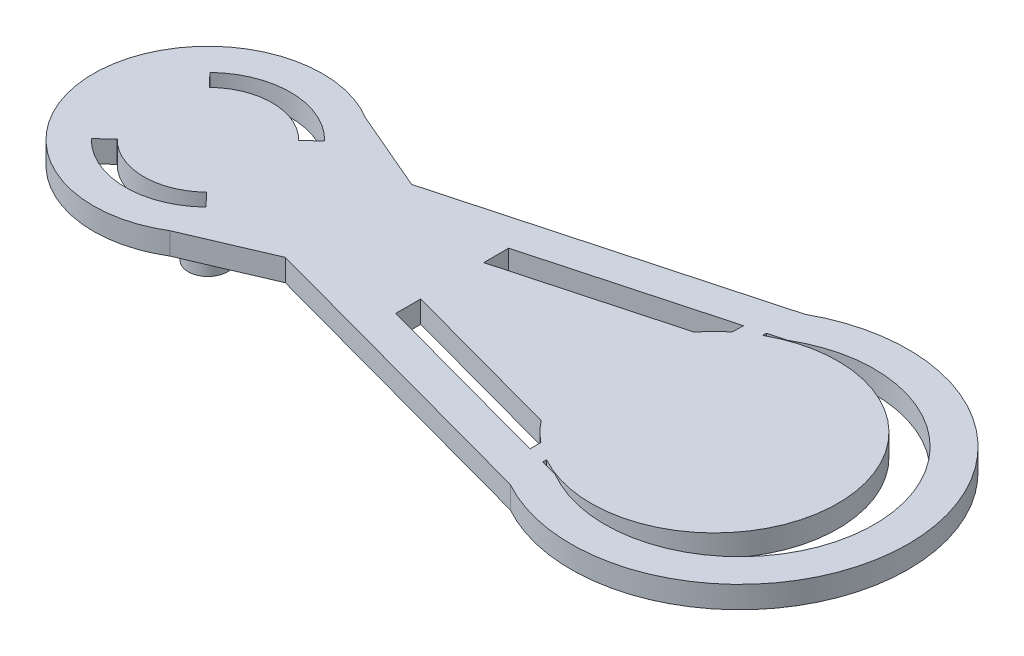
from build123d import *

# Parameters (mm, degrees)
BOSS_EXTRUDE1_DEPTH = 2.4
BOSS_EXTRUDE2_DEPTH = 9
SKETCH2_R           = 2.150011747
BOSS_EXTRUDE3_DEPTH = 9
CUT_EXTRUDE1_DEPTH  = 10


with BuildPart() as part:
    # Sketch1 → Boss-Extrude1 (new body)
    with BuildSketch(Plane(origin=(0, 0, 0), x_dir=(1, 0, 0), z_dir=(0, 1, 0))):
        with BuildLine():
            Line((-39.556221528, -6.891215643), (-5.823918226, -16.078704856))
            ThreePointArc((-5.823918226, -16.078704856), (21.515277807, 0.00207027), (-5.827536633, 16.076692097))
            Line((-5.827536633, 16.076692097), (-39.556221528, 6.891215643))
            Line((-39.556221528, 6.891215643), (-48.371159118, 10.670216357))
            ThreePointArc((-48.371159118, 10.670216357), (-67.382417284, 0), (-48.371159118, -10.670216357))
            Line((-48.371159118, -10.670216357), (-39.556221528, -6.891215643))
        make_face()
        with BuildLine():
            Line((-8.122758878, -10.441521159), (-8.105229312, -11.643301988))
            Line((-8.105229312, -11.643301988), (-28.234913418, -6.160686291))
            Line((-28.234913418, -6.160686291), (-28.234913418, -3.434881235))
            Line((-28.234913418, -3.434881235), (-26.602273601, -3.879554715))
            Line((-26.602273601, -3.879554715), (-10.183921919, -8.35133441))
            ThreePointArc((-10.183921919, -8.35133441), (-9.210480376, -9.452774334), (-8.122758878, -10.441521159))
        make_face(mode=Mode.SUBTRACT)
        with BuildLine():
            Line((-28.234913418, 6.161641155), (-8.104625251, 11.643808294))
            Line((-8.104625251, 11.643808294), (-8.119473087, 10.444385808))
            ThreePointArc((-8.119473087, 10.444385808), (-9.209489158, 9.453970662), (-10.184798219, 8.350417567))
            Line((-10.184798219, 8.350417567), (-26.60206646, 3.879432964))
            Line((-26.60206646, 3.879432964), (-28.234913418, 3.434752795))
            Line((-28.234913418, 3.434752795), (-28.234913418, 6.161641155))
        make_face(mode=Mode.SUBTRACT)
        with BuildLine():
            Line((-4.336944207, -12.669649891), (-6.180251244, -12.167598093))
            Line((-6.180251244, -12.167598093), (-6.180251244, -11.758725803))
            ThreePointArc((-6.180251244, -11.758725803), (13.838310708, -0.01960386), (-6.145811005, 11.778052091))
            Line((-6.145811005, 11.778052091), (-6.145811005, 12.177260522))
            Line((-6.145811005, 12.177260522), (-4.336225757, 12.670072583))
            ThreePointArc((-4.336225757, 12.670072583), (17.81758271, -0.000416785), (-4.336944207, -12.669649891))
        make_face(mode=Mode.SUBTRACT)
    extrude(amount=BOSS_EXTRUDE1_DEPTH)



with BuildPart() as body_2:
    # Sketch1_4 → Boss-Extrude2 (new body)
    with BuildSketch(Plane(origin=(0, 0, 0), x_dir=(1, 0, 0), z_dir=(0, 1, 0))):
        with BuildLine():
            ThreePointArc((-57.032417284, 0), (-54.882417284, -2.15), (-52.732417284, 0))
            Line((-52.732417284, 0), (-57.032417284, 0))
        make_face()
        with BuildLine():
            Line((-57.032417284, 0), (-52.732417284, 0))
            ThreePointArc((-52.732417284, 0), (-54.882417284, 2.15), (-57.032417284, 0))
        make_face()
    extrude(amount=-BOSS_EXTRUDE2_DEPTH)


with BuildPart() as part_1:
    add(part.part)

    add(body_2.part)  # Boss-Extrude3 merges body 2
    # Sketch2 → Boss-Extrude3 (add)
    with BuildSketch(Plane(origin=(0, 2.4, 0), x_dir=(1, 0, 0), z_dir=(0, 1, 0))):
        with Locations((-54.882419847, 1.1464e-05)):
            Circle(SKETCH2_R)
    extrude(amount=-BOSS_EXTRUDE3_DEPTH)

    # Sketch3 → Cut-Extrude1 (cut)
    with BuildSketch(Plane(origin=(0, 2.4, 0), x_dir=(1, 0, 0), z_dir=(0, 1, 0))):
        with BuildLine():
            ThreePointArc((-48.415945495, 6.259771763), (-54.736258294, 8.998813115), (-61.142189047, 6.466471789))
            Line((-61.142189047, 6.466471789), (-59.751128654, 5.029478057))
            ThreePointArc((-59.751128654, 5.029478057), (-54.768738069, 6.999076866), (-49.852939226, 4.86871137))
            Line((-49.852939226, 4.86871137), (-48.415945495, 6.259771763))
        make_face()
        with BuildLine():
            Line((-59.911895341, -4.86871137), (-61.348889073, -6.259771763))
            ThreePointArc((-61.348889073, -6.259771763), (-55.028576274, -8.998813115), (-48.622645521, -6.466471789))
            Line((-48.622645521, -6.466471789), (-50.013705914, -5.029478057))
            ThreePointArc((-50.013705914, -5.029478057), (-54.996096499, -6.999076866), (-59.911895341, -4.86871137))
        make_face()
    extrude(amount=-CUT_EXTRUDE1_DEPTH, mode=Mode.SUBTRACT)


solid = part_1.part
